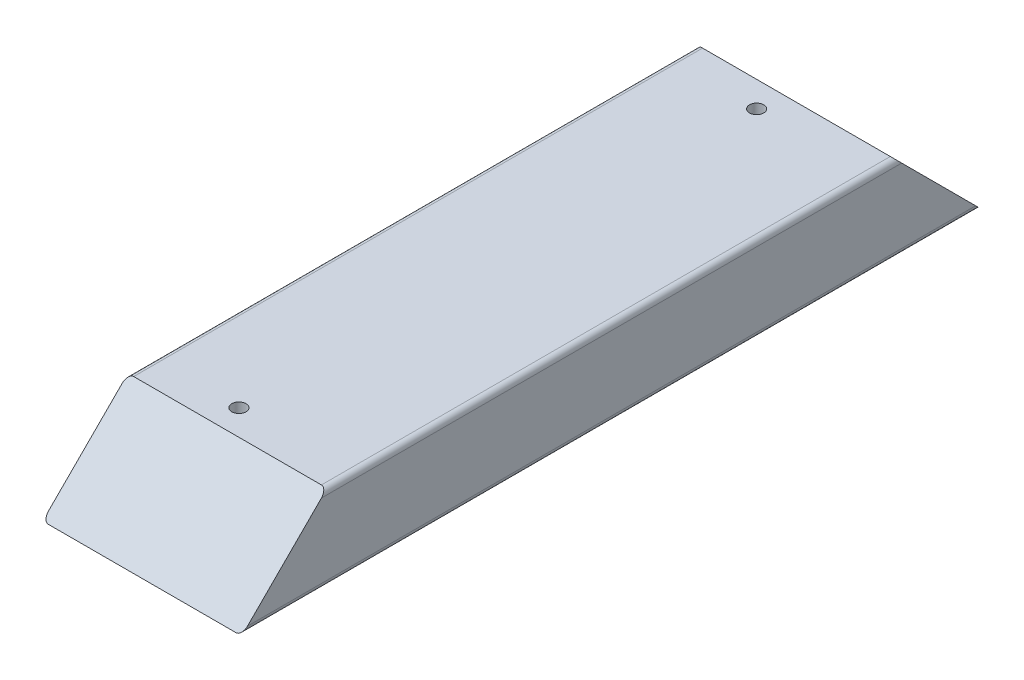
from build123d import *

# Parameters (mm, degrees)
SKETCH1_W           = 88.9
SKETCH1_H           = 38.1
BOSS_EXTRUDE1_DEPTH = 330.2
FILLET1_R           = 2.54
CUT_EXTRUDE1_DEPTH  = 406.4
SKETCH3_R           = 3.175
CUT_EXTRUDE2_DEPTH  = 12.7


with BuildPart() as part:
    # Sketch1 → Boss-Extrude1 (new body)
    with BuildSketch(Plane.XY):
        Rectangle(SKETCH1_W, SKETCH1_H)
    extrude(amount=BOSS_EXTRUDE1_DEPTH)

    # Fillet1
    fillet1_edges = [part.edges().sort_by_distance(p)[0] for p in [
        (44.45, -19.05, 165.1),
        (-44.45, -19.05, 165.1),
        (-44.45, 19.05, 165.1),
        (44.45, 19.05, 165.1),
    ]]
    fillet(fillet1_edges, radius=FILLET1_R)

    # Sketch2 → Cut-Extrude1 (cut)
    with BuildSketch(Plane.ZY.offset(44.45)):
        Polygon((0, 19.05), (0, -19.05), (38.1, 19.05), align=None)
    cut_extrude1 = extrude(amount=-CUT_EXTRUDE1_DEPTH, mode=Mode.SUBTRACT)

    # Mirror1: Cut-Extrude1 across plane
    add(cut_extrude1.mirror(Plane.XY.offset(165.1)), mode=Mode.SUBTRACT)

    # Sketch3 → Cut-Extrude2 (cut)
    with BuildSketch(Plane(origin=(0, 19.05, 0), x_dir=(1, 0, 0), z_dir=(0, 1, 0))):
        with Locations((-6.35, -49.53)):
            Circle(SKETCH3_R)
    cut_extrude2 = extrude(amount=-CUT_EXTRUDE2_DEPTH, mode=Mode.SUBTRACT)

    # Mirror4: Cut-Extrude2 across plane
    add(cut_extrude2.mirror(Plane.XY.offset(165.1)), mode=Mode.SUBTRACT)


solid = part.part
